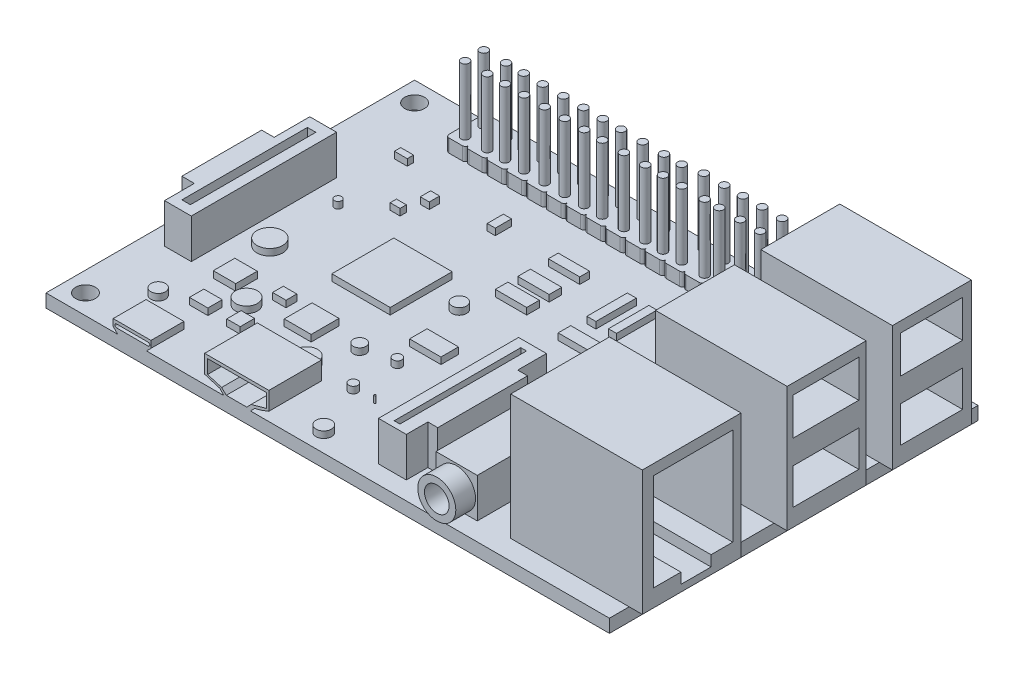
from build123d import *

# Parameters (mm, degrees)
SKETCH_1_W          = 85.6
SKETCH_1_H          = 56
SKETCH_1_R          = 1.5
EXTRUDE_1_DEPTH     = 2
SKETCH_2_W          = 20
SKETCH_2_H          = 15
SKETCH_2_H_2        = 12
EXTRUDE_2_DEPTH     = 19
SKETCH_3_W          = 9.976227017
SKETCH_3_H          = 5.662182901
SKETCH_3_H_2        = 5.459962083
SKETCH_3_W_2        = 9.436971503
CUT_EXTRUDE_1_DEPTH = 18
SKETCH_4_W          = 0.874560158
SKETCH_4_H          = 19.24032348
SKETCH_4_W_2        = 6.277002162
SKETCH_4_H_2        = 15.01022256
SKETCH_4_W_3        = 1.28566498
SKETCH_4_H_3        = 19.064574987
EXTRUDE_3_DEPTH     = 6
SKETCH_5_R          = 2.890927395
SKETCH_5_R_2        = 1.868229304
EXTRUDE_4_DEPTH     = 3
EXTRUDE_5_DEPTH     = 5
EXTRUDE_6_DEPTH     = 8
EXTRUDE_7_DEPTH     = 2
SKETCH_9_R          = 0.545826275
SKETCH_9_R_2        = 1.954951688
SKETCH_9_R_3        = 1.095513724
SKETCH_9_R_4        = 0.955195981
SKETCH_9_R_5        = 1.665664695
SKETCH_9_R_6        = 0.682282844
SKETCH_9_R_7        = 0.136456569
SKETCH_9_R_8        = 1.173843789
SKETCH_9_R_9        = 1.100148029
SKETCH_9_W          = 8.869676967
SKETCH_9_H          = 9.415503242
SKETCH_9_W_2        = 6.822828436
SKETCH_9_H_2        = 10.507155792
SKETCH_9_W_3        = 3.411414218
SKETCH_9_H_3        = 3.274957649
SKETCH_9_W_4        = 2.797359659
SKETCH_9_H_4        = 2.1833051
SKETCH_9_W_5        = 4.093697062
SKETCH_9_H_5        = 4.230153631
SKETCH_9_W_6        = 2.046848531
SKETCH_9_H_6        = 1.637478825
SKETCH_9_W_7        = 1.228109118
SKETCH_9_H_7        = 6.140545593
SKETCH_9_W_8        = 1.364565687
SKETCH_9_W_9        = 4.767484427
SKETCH_9_H_8        = 1.501022256
SKETCH_9_H_9        = 1.910391963
SKETCH_9_H_10       = 1.910391962
SKETCH_9_W_10       = 4.503066768
SKETCH_9_W_11       = 2.364565687
SKETCH_9_H_11       = 5.321806181
SKETCH_9_H_12       = 5.32180618
SKETCH_9_H_13       = 2.66090309
SKETCH_9_W_12       = 1.501022255
SKETCH_9_H_14       = 0.955195981
SKETCH_9_W_13       = 1.364565688
SKETCH_9_H_15       = 1.56925054
SKETCH_9_W_14       = 1.954951689
SKETCH_9_W_15       = 1.228109119
SKETCH_9_H_16       = 2.456218237
EXTRUDE_9_DEPTH     = 1
SKETCH_10_R         = 0.619045763
EXTRUDE_10_DEPTH    = 10


with BuildPart() as part:
    # 草图1 → 凸台-拉伸1 (new body)
    with BuildSketch(Plane(origin=(0, 0, 0), x_dir=(1, 0, 0), z_dir=(0, 1, 0))):
        Rectangle(SKETCH_1_W, SKETCH_1_H)
        with Locations((-39.8, 25)):
            Circle(SKETCH_1_R, mode=Mode.SUBTRACT)
        with Locations((-39.8, -25)):
            Circle(SKETCH_1_R, mode=Mode.SUBTRACT)
    extrude(amount=EXTRUDE_1_DEPTH)

    # 草图2 → 凸台-拉伸2 (add)
    with BuildSketch(Plane(origin=(0, 2, 0), x_dir=(1, 0, 0), z_dir=(0, 1, 0))):
        with Locations((34.8, -17.5)):
            Rectangle(SKETCH_2_W, SKETCH_2_H)
        with Locations((34.8, 3)):
            Rectangle(SKETCH_2_W, SKETCH_2_H_2)
        with Locations((34.8, 19)):
            Rectangle(SKETCH_2_W, SKETCH_2_H_2)
    extrude(amount=EXTRUDE_2_DEPTH)

    # 草图3 → 切除-拉伸1 (cut)
    with BuildSketch(Plane(origin=(44.8, 0, 0), x_dir=(0, 0, -1), z_dir=(1, 0, 0))):
        Polygon((-23.322800999, 19.397715988), (-23.322800999, 4.635596281), (-19.143570762, 4.635596281), (-19.143570762, 3.017829737), (-14.55989889, 3.017829737), (-14.55989889, 4.635596281), (-11.256958864, 4.635596281), (-11.256958864, 19.397715988), align=None)
        with Locations((2.898498391, 16.566624538)):
            Rectangle(SKETCH_3_W, SKETCH_3_H)
        with Locations((2.898498391, 7.365577323)):
            Rectangle(SKETCH_3_W, SKETCH_3_H_2)
        with Locations((18.941349945, 16.566624538)):
            Rectangle(SKETCH_3_W_2, SKETCH_3_H)
        with Locations((18.941349945, 7.365577323)):
            Rectangle(SKETCH_3_W_2, SKETCH_3_H_2)
    extrude(amount=-CUT_EXTRUDE_1_DEPTH, mode=Mode.SUBTRACT)

    # 草图4 → 凸台-拉伸3 (add)
    with BuildSketch(Plane(origin=(0, 2, 0), x_dir=(1, 0, 0), z_dir=(0, 1, 0))):
        Polygon((4.957240493, -25.244465214), (4.957240493, -3.957240493), (9.187394123, -3.957240493), (9.187394123, -8.323850692), (10.688416379, -8.323850692), (10.688416379, -21.969507565), (9.187394123, -21.969507565), (9.187394123, -25.244465214), align=None)
        with Locations((6.907037206, -14.750904962)):
            Rectangle(SKETCH_4_W, SKETCH_4_H, mode=Mode.SUBTRACT)
        with Locations((16.828961972, -17.739353934)):
            Rectangle(SKETCH_4_W_2, SKETCH_4_H_2)
        Polygon((-35.879952754, -12.847485286), (-35.879952754, 9.217351929), (-39.940965738, 9.217351929), (-39.940965738, 3.80266795), (-41.836105131, 3.80266795), (-41.836105131, -8.323850692), (-39.940965738, -8.323850692), (-39.940965738, -12.847485286), align=None)
        with Locations((-38.077709306, -1.899426108)):
            Rectangle(SKETCH_4_W_3, SKETCH_4_H_3, mode=Mode.SUBTRACT)
    extrude(amount=EXTRUDE_3_DEPTH)

    # 草图5 → 凸台-拉伸4 (add)
    with BuildSketch(Plane.XY.offset(25.244465214)):
        with Locations((16.816556829, 4.813446802)):
            Circle(SKETCH_5_R)
        with Locations((16.816556829, 4.813446802)):
            Circle(SKETCH_5_R_2, mode=Mode.SUBTRACT)
    extrude(amount=EXTRUDE_4_DEPTH)

    # 草图6 → 凸台-拉伸5 (add)
    with BuildSketch(Plane.XY.offset(28)):
        Polygon((-31.913186275, 2), (-32.595957108, 2.682770834), (-32.595957108, 3.72728973), (-26.84871339, 3.72728973), (-26.84871339, 2.682770834), (-27.531484223, 2), align=None)
        with BuildLine():
            Line((-32.093042174, 3.273837728), (-27.285258393, 3.273837728))
            ThreePointArc((-27.285258393, 3.273837728), (-27.028097865, 3.0166772), (-27.285258393, 2.759516672))
            Line((-27.285258393, 2.759516672), (-32.093042174, 2.759516672))
            ThreePointArc((-32.093042174, 2.759516672), (-32.350202702, 3.0166772), (-32.093042174, 3.273837728))
        make_face(mode=Mode.SUBTRACT)
    extrude(amount=-EXTRUDE_5_DEPTH)

    # 草图7 → 凸台-拉伸6 (add)
    with BuildSketch(Plane.XY.offset(28)):
        Polygon((-18.695682778, 6.107053167), (-18.695682778, 3.354753319), (-17.209433461, 2.904849557), (-16.391834648, 2.657353543), (-15.775356525, 2), (-11.739879472, 2), (-11.082525929, 2.657353543), (-10.123522165, 2.904849557), (-8.940821697, 3.354753319), (-8.940821697, 6.107053167), align=None)
        Polygon((-18.244732049, 5.633816389), (-18.244732049, 3.544378895), (-16.115871206, 2.904849557), (-15.406250925, 2.223696705), (-12.291806358, 2.223696705), (-11.637978923, 2.904849557), (-9.315343512, 3.544378895), (-9.315343512, 5.633816389), align=None, mode=Mode.SUBTRACT)
    extrude(amount=-EXTRUDE_6_DEPTH)

    # 草图8 → 凸台-拉伸7 (add)
    with BuildSketch(Plane(origin=(0, 2, 0), x_dir=(1, 0, 0), z_dir=(0, 1, 0))):
        with BuildLine():
            Line((-24.558191378, 21), (-22.558191378, 21))
            ThreePointArc((-22.558191378, 21), (-22.204637988, 21.146446609), (-22.058191378, 21.5))
            ThreePointArc((-22.058191378, 21.5), (-21.911744769, 21.146446609), (-21.558191378, 21))
            Line((-21.558191378, 21), (-19.558191378, 21))
            ThreePointArc((-19.558191378, 21), (-19.204637988, 21.146446609), (-19.058191378, 21.5))
            ThreePointArc((-19.058191378, 21.5), (-18.911744769, 21.146446609), (-18.558191378, 21))
            Line((-18.558191378, 21), (-16.558191378, 21))
            ThreePointArc((-16.558191378, 21), (-16.204637988, 21.146446609), (-16.058191378, 21.5))
            ThreePointArc((-16.058191378, 21.5), (-15.911744769, 21.146446609), (-15.558191378, 21))
            Line((-15.558191378, 21), (-13.558191378, 21))
            ThreePointArc((-13.558191378, 21), (-13.204637988, 21.146446609), (-13.058191378, 21.5))
            ThreePointArc((-13.058191378, 21.5), (-12.911744769, 21.146446609), (-12.558191378, 21))
            Line((-12.558191378, 21), (-10.558191378, 21))
            ThreePointArc((-10.558191378, 21), (-10.204637988, 21.146446609), (-10.058191378, 21.5))
            ThreePointArc((-10.058191378, 21.5), (-9.911744769, 21.146446609), (-9.558191378, 21))
            Line((-9.558191378, 21), (-7.558191378, 21))
            ThreePointArc((-7.558191378, 21), (-7.204637988, 21.146446609), (-7.058191378, 21.5))
            ThreePointArc((-7.058191378, 21.5), (-6.911744769, 21.146446609), (-6.558191378, 21))
            Line((-6.558191378, 21), (-4.558191378, 21))
            ThreePointArc((-4.558191378, 21), (-4.204637988, 21.146446609), (-4.058191378, 21.5))
            ThreePointArc((-4.058191378, 21.5), (-3.911744769, 21.146446609), (-3.558191378, 21))
            Line((-3.558191378, 21), (-1.558191378, 21))
            ThreePointArc((-1.558191378, 21), (-1.204637988, 21.146446609), (-1.058191378, 21.5))
            ThreePointArc((-1.058191378, 21.5), (-0.911744769, 21.146446609), (-0.558191378, 21))
            Line((-0.558191378, 21), (1.441808622, 21))
            ThreePointArc((1.441808622, 21), (1.795362012, 21.146446609), (1.941808622, 21.5))
            ThreePointArc((1.941808622, 21.5), (2.088255231, 21.146446609), (2.441808622, 21))
            Line((2.441808622, 21), (4.441808622, 21))
            ThreePointArc((4.441808622, 21), (4.795362012, 21.146446609), (4.941808622, 21.5))
            ThreePointArc((4.941808622, 21.5), (5.088255231, 21.146446609), (5.441808622, 21))
            Line((5.441808622, 21), (7.441808622, 21))
            ThreePointArc((7.441808622, 21), (7.795362012, 21.146446609), (7.941808622, 21.5))
            ThreePointArc((7.941808622, 21.5), (8.088255231, 21.146446609), (8.441808622, 21))
            Line((8.441808622, 21), (10.441808622, 21))
            ThreePointArc((10.441808622, 21), (10.795362012, 21.146446609), (10.941808622, 21.5))
            ThreePointArc((10.941808622, 21.5), (11.088255231, 21.146446609), (11.441808622, 21))
            Line((11.441808622, 21), (13.441808622, 21))
            ThreePointArc((13.441808622, 21), (13.795362012, 21.146446609), (13.941808622, 21.5))
            ThreePointArc((13.941808622, 21.5), (14.088255231, 21.146446609), (14.441808622, 21))
            Line((14.441808622, 21), (16.441808622, 21))
            ThreePointArc((16.441808622, 21), (16.795362012, 21.146446609), (16.941808622, 21.5))
            Line((16.941808622, 21.5), (16.941808622, 23.5))
            ThreePointArc((16.941808622, 23.5), (16.795362012, 23.853553391), (16.441808622, 24))
            ThreePointArc((16.441808622, 24), (16.795362012, 24.146446609), (16.941808622, 24.5))
            Line((16.941808622, 24.5), (16.941808622, 26.5))
            ThreePointArc((16.941808622, 26.5), (16.795362012, 26.853553391), (16.441808622, 27))
            Line((16.441808622, 27), (14.441808622, 27))
            ThreePointArc((14.441808622, 27), (14.088255231, 26.853553391), (13.941808622, 26.5))
            ThreePointArc((13.941808622, 26.5), (13.795362012, 26.853553391), (13.441808622, 27))
            Line((13.441808622, 27), (11.441808622, 27))
            ThreePointArc((11.441808622, 27), (11.088255231, 26.853553391), (10.941808622, 26.5))
            ThreePointArc((10.941808622, 26.5), (10.795362012, 26.853553391), (10.441808622, 27))
            Line((10.441808622, 27), (8.441808622, 27))
            ThreePointArc((8.441808622, 27), (8.088255231, 26.853553391), (7.941808622, 26.5))
            ThreePointArc((7.941808622, 26.5), (7.795362012, 26.853553391), (7.441808622, 27))
            Line((7.441808622, 27), (5.441808622, 27))
            ThreePointArc((5.441808622, 27), (5.088255231, 26.853553391), (4.941808622, 26.5))
            ThreePointArc((4.941808622, 26.5), (4.795362012, 26.853553391), (4.441808622, 27))
            Line((4.441808622, 27), (2.441808622, 27))
            ThreePointArc((2.441808622, 27), (2.088255231, 26.853553391), (1.941808622, 26.5))
            ThreePointArc((1.941808622, 26.5), (1.795362012, 26.853553391), (1.441808622, 27))
            Line((1.441808622, 27), (-0.558191378, 27))
            ThreePointArc((-0.558191378, 27), (-0.911744769, 26.853553391), (-1.058191378, 26.5))
            ThreePointArc((-1.058191378, 26.5), (-1.204637988, 26.853553391), (-1.558191378, 27))
            Line((-1.558191378, 27), (-3.558191378, 27))
            ThreePointArc((-3.558191378, 27), (-3.911744769, 26.853553391), (-4.058191378, 26.5))
            ThreePointArc((-4.058191378, 26.5), (-4.204637988, 26.853553391), (-4.558191378, 27))
            Line((-4.558191378, 27), (-6.558191378, 27))
            ThreePointArc((-6.558191378, 27), (-6.911744769, 26.853553391), (-7.058191378, 26.5))
            ThreePointArc((-7.058191378, 26.5), (-7.204637988, 26.853553391), (-7.558191378, 27))
            Line((-7.558191378, 27), (-9.558191378, 27))
            ThreePointArc((-9.558191378, 27), (-9.911744769, 26.853553391), (-10.058191378, 26.5))
            ThreePointArc((-10.058191378, 26.5), (-10.204637988, 26.853553391), (-10.558191378, 27))
            Line((-10.558191378, 27), (-12.558191378, 27))
            ThreePointArc((-12.558191378, 27), (-12.911744769, 26.853553391), (-13.058191378, 26.5))
            ThreePointArc((-13.058191378, 26.5), (-13.204637988, 26.853553391), (-13.558191378, 27))
            Line((-13.558191378, 27), (-15.558191378, 27))
            ThreePointArc((-15.558191378, 27), (-15.911744769, 26.853553391), (-16.058191378, 26.5))
            ThreePointArc((-16.058191378, 26.5), (-16.204637988, 26.853553391), (-16.558191378, 27))
            Line((-16.558191378, 27), (-18.558191378, 27))
            ThreePointArc((-18.558191378, 27), (-18.911744769, 26.853553391), (-19.058191378, 26.5))
            ThreePointArc((-19.058191378, 26.5), (-19.204637988, 26.853553391), (-19.558191378, 27))
            Line((-19.558191378, 27), (-21.558191378, 27))
            ThreePointArc((-21.558191378, 27), (-21.911744769, 26.853553391), (-22.058191378, 26.5))
            ThreePointArc((-22.058191378, 26.5), (-22.204637988, 26.853553391), (-22.558191378, 27))
            Line((-22.558191378, 27), (-24.558191378, 27))
            ThreePointArc((-24.558191378, 27), (-24.911744769, 26.853553391), (-25.058191378, 26.5))
            ThreePointArc((-25.058191378, 26.5), (-25.204637988, 26.853553391), (-25.558191378, 27))
            Line((-25.558191378, 27), (-27.558191378, 27))
            ThreePointArc((-27.558191378, 27), (-27.911744769, 26.853553391), (-28.058191378, 26.5))
            ThreePointArc((-28.058191378, 26.5), (-28.204637988, 26.853553391), (-28.558191378, 27))
            Line((-28.558191378, 27), (-30.558191378, 27))
            ThreePointArc((-30.558191378, 27), (-30.911744769, 26.853553391), (-31.058191378, 26.5))
            Line((-31.058191378, 26.5), (-31.058191378, 24.5))
            ThreePointArc((-31.058191378, 24.5), (-30.911744769, 24.146446609), (-30.558191378, 24))
            ThreePointArc((-30.558191378, 24), (-30.911744769, 23.853553391), (-31.058191378, 23.5))
            Line((-31.058191378, 23.5), (-31.058191378, 21.5))
            ThreePointArc((-31.058191378, 21.5), (-30.911744769, 21.146446609), (-30.558191378, 21))
            Line((-30.558191378, 21), (-28.558191378, 21))
            ThreePointArc((-28.558191378, 21), (-28.204637988, 21.146446609), (-28.058191378, 21.5))
            ThreePointArc((-28.058191378, 21.5), (-27.911744769, 21.146446609), (-27.558191378, 21))
            Line((-27.558191378, 21), (-25.558191378, 21))
            ThreePointArc((-25.558191378, 21), (-25.204637988, 21.146446609), (-25.058191378, 21.5))
            ThreePointArc((-25.058191378, 21.5), (-24.911744769, 21.146446609), (-24.558191378, 21))
        make_face()
        with BuildLine():
            ThreePointArc((-28.558191378, 24), (-28.204637988, 24.146446609), (-28.058191378, 24.5))
            ThreePointArc((-28.058191378, 24.5), (-27.911744769, 24.146446609), (-27.558191378, 24))
            ThreePointArc((-27.558191378, 24), (-27.911744769, 23.853553391), (-28.058191378, 23.5))
            ThreePointArc((-28.058191378, 23.5), (-28.204637988, 23.853553391), (-28.558191378, 24))
        make_face(mode=Mode.SUBTRACT)
        with BuildLine():
            ThreePointArc((-22.558191378, 24), (-22.204637988, 24.146446609), (-22.058191378, 24.5))
            ThreePointArc((-22.058191378, 24.5), (-21.911744769, 24.146446609), (-21.558191378, 24))
            ThreePointArc((-21.558191378, 24), (-21.911744769, 23.853553391), (-22.058191378, 23.5))
            ThreePointArc((-22.058191378, 23.5), (-22.204637988, 23.853553391), (-22.558191378, 24))
        make_face(mode=Mode.SUBTRACT)
        with BuildLine():
            ThreePointArc((-24.558191378, 24), (-24.911744769, 24.146446609), (-25.058191378, 24.5))
            ThreePointArc((-25.058191378, 24.5), (-25.204637988, 24.146446609), (-25.558191378, 24))
            ThreePointArc((-25.558191378, 24), (-25.204637988, 23.853553391), (-25.058191378, 23.5))
            ThreePointArc((-25.058191378, 23.5), (-24.911744769, 23.853553391), (-24.558191378, 24))
        make_face(mode=Mode.SUBTRACT)
        with BuildLine():
            ThreePointArc((-19.558191378, 24), (-19.204637988, 24.146446609), (-19.058191378, 24.5))
            ThreePointArc((-19.058191378, 24.5), (-18.911744769, 24.146446609), (-18.558191378, 24))
            ThreePointArc((-18.558191378, 24), (-18.911744769, 23.853553391), (-19.058191378, 23.5))
            ThreePointArc((-19.058191378, 23.5), (-19.204637988, 23.853553391), (-19.558191378, 24))
        make_face(mode=Mode.SUBTRACT)
        with BuildLine():
            ThreePointArc((-16.558191378, 24), (-16.204637988, 24.146446609), (-16.058191378, 24.5))
            ThreePointArc((-16.058191378, 24.5), (-15.911744769, 24.146446609), (-15.558191378, 24))
            ThreePointArc((-15.558191378, 24), (-15.911744769, 23.853553391), (-16.058191378, 23.5))
            ThreePointArc((-16.058191378, 23.5), (-16.204637988, 23.853553391), (-16.558191378, 24))
        make_face(mode=Mode.SUBTRACT)
        with BuildLine():
            ThreePointArc((-13.558191378, 24), (-13.204637988, 24.146446609), (-13.058191378, 24.5))
            ThreePointArc((-13.058191378, 24.5), (-12.911744769, 24.146446609), (-12.558191378, 24))
            ThreePointArc((-12.558191378, 24), (-12.911744769, 23.853553391), (-13.058191378, 23.5))
            ThreePointArc((-13.058191378, 23.5), (-13.204637988, 23.853553391), (-13.558191378, 24))
        make_face(mode=Mode.SUBTRACT)
        with BuildLine():
            ThreePointArc((-10.558191378, 24), (-10.204637988, 24.146446609), (-10.058191378, 24.5))
            ThreePointArc((-10.058191378, 24.5), (-9.911744769, 24.146446609), (-9.558191378, 24))
            ThreePointArc((-9.558191378, 24), (-9.911744769, 23.853553391), (-10.058191378, 23.5))
            ThreePointArc((-10.058191378, 23.5), (-10.204637988, 23.853553391), (-10.558191378, 24))
        make_face(mode=Mode.SUBTRACT)
        with BuildLine():
            ThreePointArc((-7.558191378, 24), (-7.204637988, 24.146446609), (-7.058191378, 24.5))
            ThreePointArc((-7.058191378, 24.5), (-6.911744769, 24.146446609), (-6.558191378, 24))
            ThreePointArc((-6.558191378, 24), (-6.911744769, 23.853553391), (-7.058191378, 23.5))
            ThreePointArc((-7.058191378, 23.5), (-7.204637988, 23.853553391), (-7.558191378, 24))
        make_face(mode=Mode.SUBTRACT)
        with BuildLine():
            ThreePointArc((-4.558191378, 24), (-4.204637988, 24.146446609), (-4.058191378, 24.5))
            ThreePointArc((-4.058191378, 24.5), (-3.911744769, 24.146446609), (-3.558191378, 24))
            ThreePointArc((-3.558191378, 24), (-3.911744769, 23.853553391), (-4.058191378, 23.5))
            ThreePointArc((-4.058191378, 23.5), (-4.204637988, 23.853553391), (-4.558191378, 24))
        make_face(mode=Mode.SUBTRACT)
        with BuildLine():
            ThreePointArc((1.441808622, 24), (1.795362012, 24.146446609), (1.941808622, 24.5))
            ThreePointArc((1.941808622, 24.5), (2.088255231, 24.146446609), (2.441808622, 24))
            ThreePointArc((2.441808622, 24), (2.088255231, 23.853553391), (1.941808622, 23.5))
            ThreePointArc((1.941808622, 23.5), (1.795362012, 23.853553391), (1.441808622, 24))
        make_face(mode=Mode.SUBTRACT)
        with BuildLine():
            ThreePointArc((-0.558191378, 24), (-0.911744769, 24.146446609), (-1.058191378, 24.5))
            ThreePointArc((-1.058191378, 24.5), (-1.204637988, 24.146446609), (-1.558191378, 24))
            ThreePointArc((-1.558191378, 24), (-1.204637988, 23.853553391), (-1.058191378, 23.5))
            ThreePointArc((-1.058191378, 23.5), (-0.911744769, 23.853553391), (-0.558191378, 24))
        make_face(mode=Mode.SUBTRACT)
        with BuildLine():
            ThreePointArc((4.441808622, 24), (4.795362012, 24.146446609), (4.941808622, 24.5))
            ThreePointArc((4.941808622, 24.5), (5.088255231, 24.146446609), (5.441808622, 24))
            ThreePointArc((5.441808622, 24), (5.088255231, 23.853553391), (4.941808622, 23.5))
            ThreePointArc((4.941808622, 23.5), (4.795362012, 23.853553391), (4.441808622, 24))
        make_face(mode=Mode.SUBTRACT)
        with BuildLine():
            ThreePointArc((7.441808622, 24), (7.795362012, 24.146446609), (7.941808622, 24.5))
            ThreePointArc((7.941808622, 24.5), (8.088255231, 24.146446609), (8.441808622, 24))
            ThreePointArc((8.441808622, 24), (8.088255231, 23.853553391), (7.941808622, 23.5))
            ThreePointArc((7.941808622, 23.5), (7.795362012, 23.853553391), (7.441808622, 24))
        make_face(mode=Mode.SUBTRACT)
        with BuildLine():
            ThreePointArc((10.441808622, 24), (10.795362012, 24.146446609), (10.941808622, 24.5))
            ThreePointArc((10.941808622, 24.5), (11.088255231, 24.146446609), (11.441808622, 24))
            ThreePointArc((11.441808622, 24), (11.088255231, 23.853553391), (10.941808622, 23.5))
            ThreePointArc((10.941808622, 23.5), (10.795362012, 23.853553391), (10.441808622, 24))
        make_face(mode=Mode.SUBTRACT)
        with BuildLine():
            ThreePointArc((13.441808622, 24), (13.795362012, 24.146446609), (13.941808622, 24.5))
            ThreePointArc((13.941808622, 24.5), (14.088255231, 24.146446609), (14.441808622, 24))
            ThreePointArc((14.441808622, 24), (14.088255231, 23.853553391), (13.941808622, 23.5))
            ThreePointArc((13.941808622, 23.5), (13.795362012, 23.853553391), (13.441808622, 24))
        make_face(mode=Mode.SUBTRACT)
    extrude(amount=EXTRUDE_7_DEPTH)

    # 草图9 → 凸台-拉伸9 (add)
    with BuildSketch(Plane(origin=(0, 2, 0), x_dir=(1, 0, 0), z_dir=(0, 1, 0))):
        with Locations((-32.022489631, 5.602566834)):
            Circle(SKETCH_9_R)
        with Locations((-32.022489631, -4.768132389)):
            Circle(SKETCH_9_R_2)
        with Locations((-33.97744132, -19.778354949)):
            Circle(SKETCH_9_R_3)
        with Locations((-11.417547754, -11.727417394)):
            Circle(SKETCH_9_R_4)
        with Locations((-26.018400608, -14.3200922)):
            Circle(SKETCH_9_R_5)
        with Locations((-13.737309422, -17.45859328)):
            Circle(SKETCH_9_R_5)
        with Locations((-6.641567849, -17.45859328)):
            Circle(SKETCH_9_R_6)
        with Locations((-3.366610199, -17.45859328)):
            Circle(SKETCH_9_R_7)
        with Locations((-3.366610199, -25.236617698)):
            Circle(SKETCH_9_R_8)
        with Locations((-6.641567849, -10.772221413)):
            Circle(SKETCH_9_R_6)
        with Locations((-9.234242654, 1.235956635)):
            Circle(SKETCH_9_R_9)
        with Locations((-18.172147906, -0.060380768)):
            Rectangle(SKETCH_9_W, SKETCH_9_H)
        with Locations((17.511244816, 9.900948749)):
            Rectangle(SKETCH_9_W_2, SKETCH_9_H_2)
        with Locations((-30.316782522, -11.727417394)):
            Rectangle(SKETCH_9_W_3, SKETCH_9_H_3)
        with Locations((-28.918102692, -17.595049849)):
            Rectangle(SKETCH_9_W_4, SKETCH_9_H_4)
        with Locations((-18.24037619, -12.205015385)):
            Rectangle(SKETCH_9_W_5, SKETCH_9_H_5)
        with Locations((-23.630410655, -17.595049849)):
            Rectangle(SKETCH_9_W_6, SKETCH_9_H_4)
        with Locations((-23.630410655, -10.908677982)):
            Rectangle(SKETCH_9_W_6, SKETCH_9_H_6)
        with Locations((6.253577896, 12.084253849)):
            Rectangle(SKETCH_9_W_7, SKETCH_9_H_7)
        with Locations((3.046848531, 12.084253849)):
            Rectangle(SKETCH_9_W_8, SKETCH_9_H_7)
        with Locations((-5.750352413, 14.404015517)):
            Rectangle(SKETCH_9_W_9, SKETCH_9_H_8)
        with Locations((-5.750352413, 9.969177033)):
            Rectangle(SKETCH_9_W_9, SKETCH_9_H_9)
        with Locations((-5.750352413, 6.557762815)):
            Rectangle(SKETCH_9_W_9, SKETCH_9_H_10)
        with Locations((4.616099071, 5.602566834)):
            Rectangle(SKETCH_9_W_10, SKETCH_9_H_10)
        with Locations((1.182282844, -16.025799309)):
            Rectangle(SKETCH_9_W_11, SKETCH_9_H_11)
        with Locations((1.182282844, -7.429035479)):
            Rectangle(SKETCH_9_W_11, SKETCH_9_H_12)
        with Locations((-5.750352413, -6.098583934)):
            Rectangle(SKETCH_9_W_9, SKETCH_9_H_13)
        with Locations((-26.768911736, 9.491579042)):
            Rectangle(SKETCH_9_W_12, SKETCH_9_H_14)
        with Locations((-25.336117764, 12.868879119)):
            Rectangle(SKETCH_9_W_13, SKETCH_9_H_15)
        with Locations((-32.999965476, 16.587320617)):
            Rectangle(SKETCH_9_W_14, SKETCH_9_H_14)
        with Locations((-16.807582219, 14.881613507)):
            Rectangle(SKETCH_9_W_15, SKETCH_9_H_16)
    extrude(amount=EXTRUDE_9_DEPTH)

    # 草图10 → 凸台-拉伸10 (add)
    with BuildSketch(Plane(origin=(0, 4, 0), x_dir=(1, 0, 0), z_dir=(0, 1, 0))):
        with Locations((-29.512685624, 22.387843602)):
            Circle(SKETCH_10_R)
        with Locations((-29.512685624, 25.228821149)):
            Circle(SKETCH_10_R)
        with Locations((-26.134225838, 22.387843602)):
            Circle(SKETCH_10_R)
        with Locations((-26.134225838, 25.228821149)):
            Circle(SKETCH_10_R)
        with Locations((-23.446814645, 22.387843602)):
            Circle(SKETCH_10_R)
        with Locations((-23.446814645, 25.228821149)):
            Circle(SKETCH_10_R)
        with Locations((-20.558191378, 22.387843602)):
            Circle(SKETCH_10_R)
        with Locations((-20.558191378, 25.228821149)):
            Circle(SKETCH_10_R)
        with Locations((-17.432737136, 22.387843602)):
            Circle(SKETCH_10_R)
        with Locations((-17.432737136, 25.228821149)):
            Circle(SKETCH_10_R)
        with Locations((-14.372356906, 22.387843602)):
            Circle(SKETCH_10_R)
        with Locations((-14.372356906, 25.228821149)):
            Circle(SKETCH_10_R)
        with Locations((-11.419990095, 22.387843602)):
            Circle(SKETCH_10_R)
        with Locations((-11.419990095, 25.228821149)):
            Circle(SKETCH_10_R)
        with Locations((-8.666370547, 22.387843602)):
            Circle(SKETCH_10_R)
        with Locations((-8.666370547, 25.228821149)):
            Circle(SKETCH_10_R)
        with Locations((-5.379319501, 22.387843602)):
            Circle(SKETCH_10_R)
        with Locations((-5.379319501, 25.228821149)):
            Circle(SKETCH_10_R)
        with Locations((-2.134957428, 22.387843602)):
            Circle(SKETCH_10_R)
        with Locations((-2.134957428, 25.228821149)):
            Circle(SKETCH_10_R)
        with Locations((0.554447974, 22.387843602)):
            Circle(SKETCH_10_R)
        with Locations((0.554447974, 25.228821149)):
            Circle(SKETCH_10_R)
        with Locations((3.410968356, 22.387843602)):
            Circle(SKETCH_10_R)
        with Locations((3.410968356, 25.729745664)):
            Circle(SKETCH_10_R)
        with Locations((6.869626125, 22.387843602)):
            Circle(SKETCH_10_R)
        with Locations((6.532196099, 25.729745664)):
            Circle(SKETCH_10_R)
        with Locations((9.105100049, 22.387843602)):
            Circle(SKETCH_10_R)
        with Locations((9.358172568, 25.729745664)):
            Circle(SKETCH_10_R)
        with Locations((12.268506545, 22.387843602)):
            Circle(SKETCH_10_R)
        with Locations((12.268506545, 25.729745664)):
            Circle(SKETCH_10_R)
        with Locations((15.305376781, 22.387843602)):
            Circle(SKETCH_10_R)
        with Locations((15.305376781, 25.729745664)):
            Circle(SKETCH_10_R)
    extrude(amount=EXTRUDE_10_DEPTH)


solid = part.part
